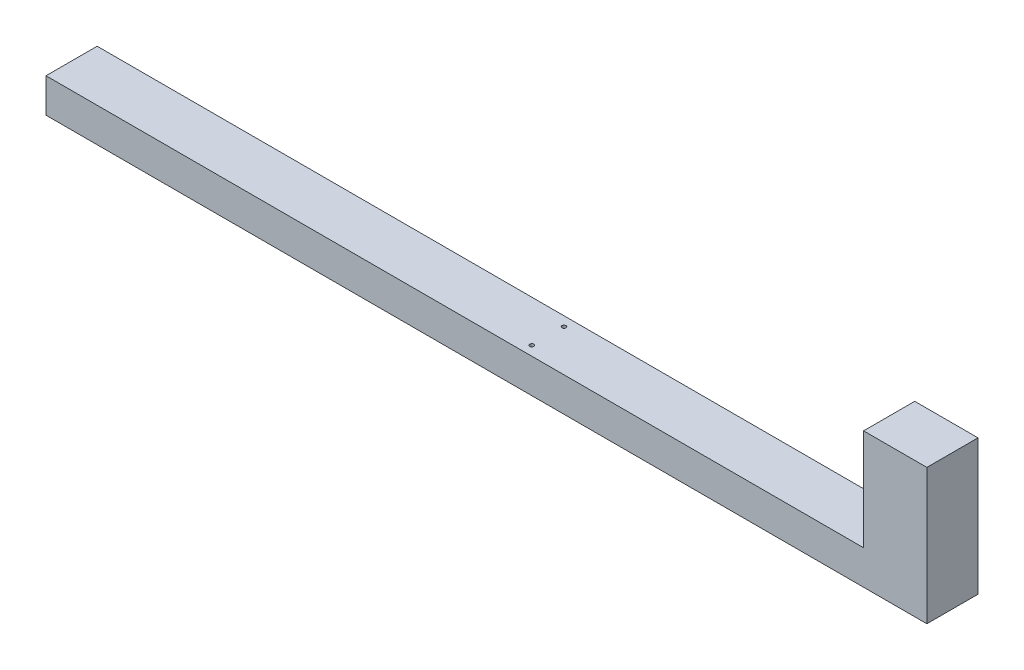
from build123d import *

# Parameters (mm, degrees)
SKETCH1_W           = 1119
SKETCH1_H           = 70
BOSS_EXTRUDE1_DEPTH = 46.8
SKETCH2_W           = 86.6
SKETCH2_H           = 70
BOSS_EXTRUDE2_DEPTH = 185.4
SKETCH4_R           = 2.75
CUT_EXTRUDE1_DEPTH  = 10


with BuildPart() as part:
    # Sketch1 → Boss-Extrude1 (new body)
    with BuildSketch(Plane(origin=(0, 0, 0), x_dir=(1, 0, 0), z_dir=(0, 1, 0))):
        Rectangle(SKETCH1_W, SKETCH1_H)
    extrude(amount=BOSS_EXTRUDE1_DEPTH)

    # Sketch2 → Boss-Extrude2 (add)
    with BuildSketch(Plane.XZ):
        with Locations((602.8, 0)):
            Rectangle(SKETCH2_W, SKETCH2_H)
    extrude(amount=-BOSS_EXTRUDE2_DEPTH)

    # Sketch4 → Cut-Extrude1 (cut)
    with BuildSketch(Plane(origin=(0, 46.8, 0), x_dir=(1, 0, 0), z_dir=(0, 1, 0))):
        with Locations((92.478641365, 22)):
            Circle(SKETCH4_R)
        with Locations((92.478641365, -22)):
            Circle(SKETCH4_R)
    extrude(amount=-CUT_EXTRUDE1_DEPTH, mode=Mode.SUBTRACT)


solid = part.part
